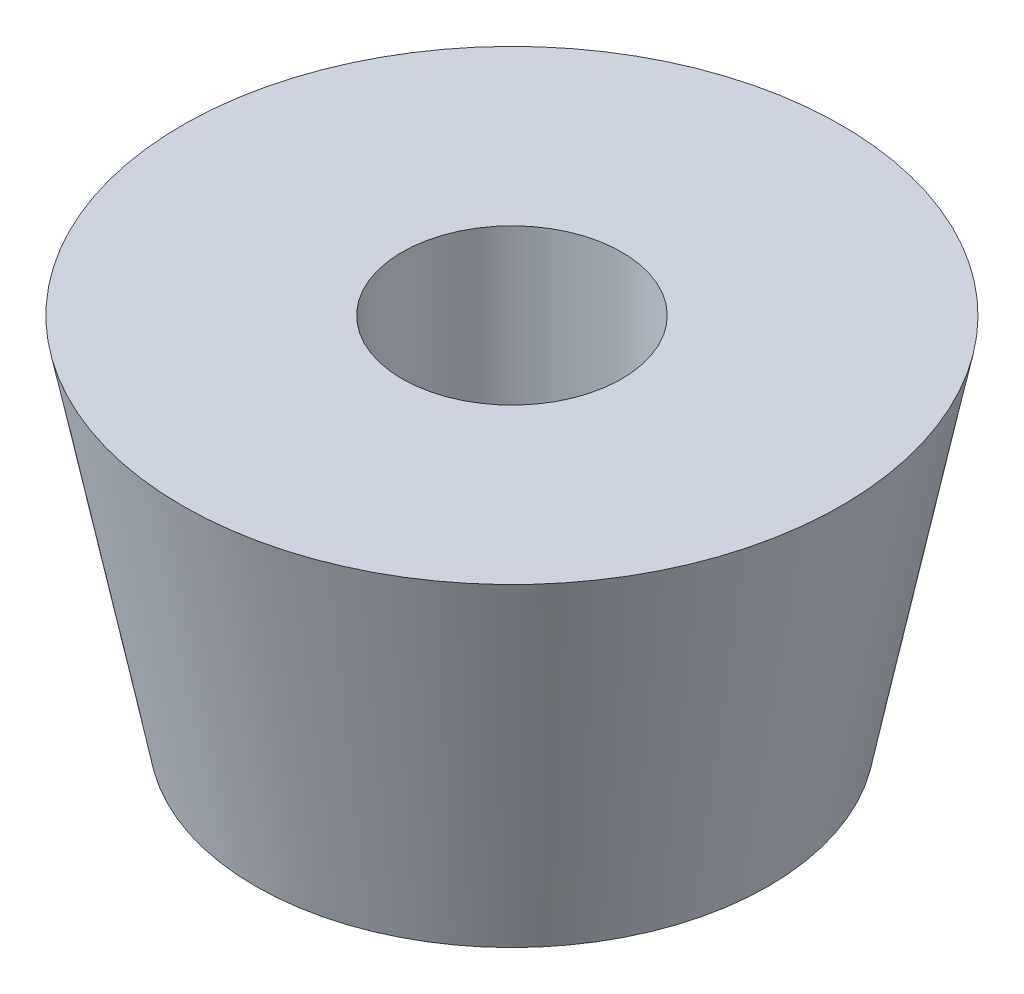
from build123d import *


with BuildPart() as part:
    # Sketch1 → Revolve1 (revolve)
    with BuildSketch(Plane(origin=(0, 0, 0), x_dir=(0, 0, -1), z_dir=(1, 0, 0))):
        Polygon((1.5, 0), (4.5, 0), (3.5, -5), (1.5, -5), align=None)
    revolve(axis=Axis((0, 0, 0), (0, -1, 0)))


solid = part.part
